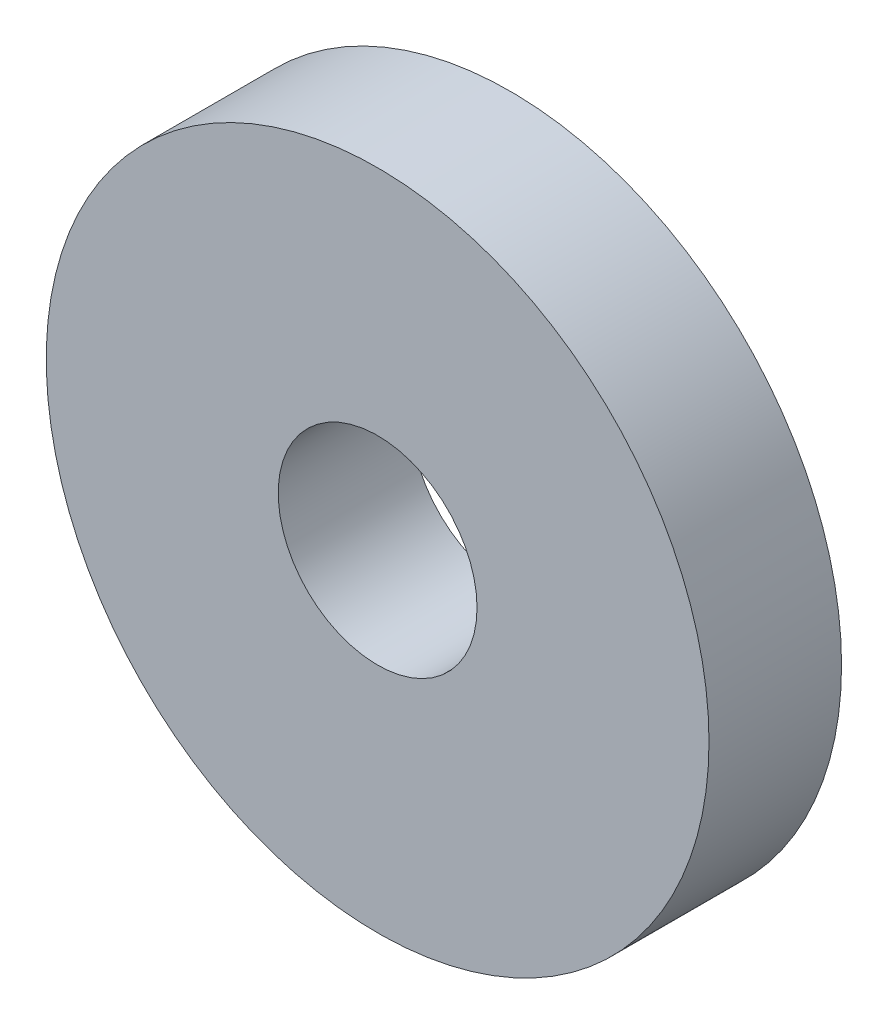
from build123d import *

# Parameters (mm, degrees)
SKETCH_1_R      = 10
SKETCH_1_R_2    = 3
EXTRUDE_1_DEPTH = 4


with BuildPart() as part:
    # 草图1 → 凸台-拉伸1 (new body)
    with BuildSketch(Plane.XY):
        Circle(SKETCH_1_R)
        Circle(SKETCH_1_R_2, mode=Mode.SUBTRACT)
    extrude(amount=EXTRUDE_1_DEPTH)


solid = part.part
